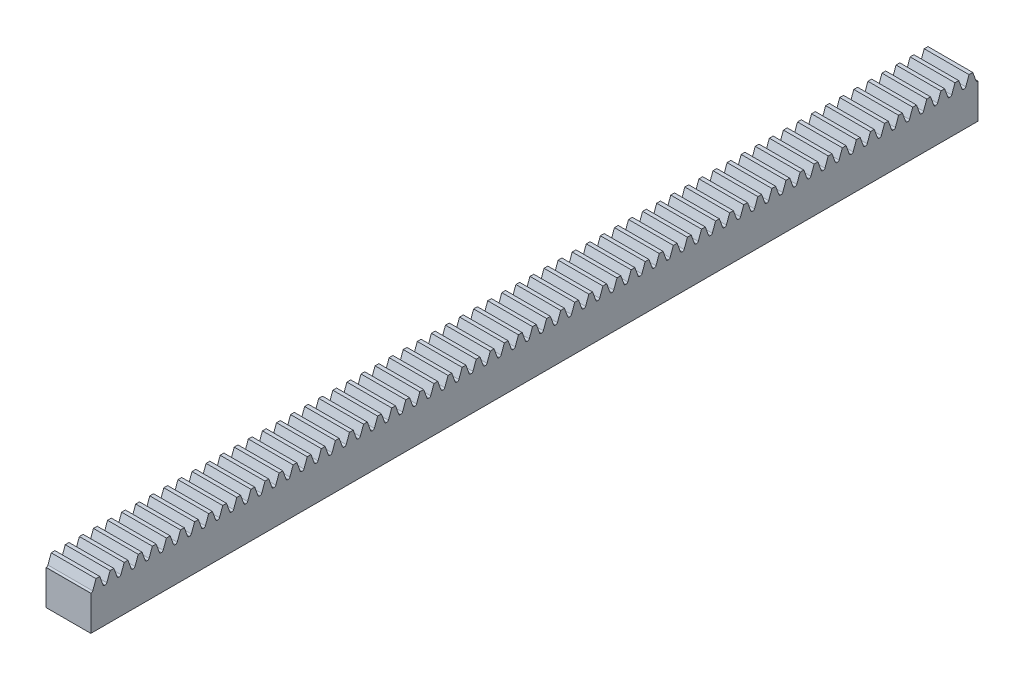
from build123d import *

# Parameters (mm, degrees)
SKETCH1_W                = 296.88
SKETCH1_H                = 15
BOSS_EXTRUDE1_DEPTH      = 15
CUT_EXTRUDE1_DEPTH       = 16
CUT_EXTRUDE2_DEPTH       = 16
CUT_EXTRUDE3_DEPTH       = 16
CUT_EXTRUDE4_DEPTH       = 16
CUT_EXTRUDE5_DEPTH       = 16
CUT_EXTRUDE6_DEPTH       = 16
CUT_EXTRUDE7_DEPTH       = 16
CUT_EXTRUDE8_DEPTH       = 16
CUT_EXTRUDE9_DEPTH       = 16
CUT_EXTRUDE10_DEPTH      = 16
CUT_EXTRUDE11_DEPTH      = 16
CUT_EXTRUDE12_DEPTH      = 16
CUT_EXTRUDE13_DEPTH      = 16
CUT_EXTRUDE14_DEPTH      = 16
CUT_EXTRUDE15_DEPTH      = 16
CUT_EXTRUDE16_DEPTH      = 16
CUT_EXTRUDE17_DEPTH      = 16
CUT_EXTRUDE18_DEPTH      = 16
CUT_EXTRUDE19_DEPTH      = 16
CUT_EXTRUDE20_DEPTH      = 16
CUT_EXTRUDE21_DEPTH      = 16
CUT_EXTRUDE22_DEPTH      = 16
CUT_EXTRUDE23_DEPTH      = 16
CUT_EXTRUDE24_DEPTH      = 16
CUT_EXTRUDE25_DEPTH      = 16
CUT_EXTRUDE26_DEPTH      = 16
CUT_EXTRUDE27_DEPTH      = 16
CUT_EXTRUDE28_DEPTH      = 16
CUT_EXTRUDE29_DEPTH      = 16
CUT_EXTRUDE30_DEPTH      = 16
CUT_EXTRUDE31_DEPTH      = 16
CUT_EXTRUDE32_DEPTH      = 16
CUT_EXTRUDE33_DEPTH      = 16
CUT_EXTRUDE34_DEPTH      = 16
CUT_EXTRUDE35_DEPTH      = 16
CUT_EXTRUDE36_DEPTH      = 16
CUT_EXTRUDE37_DEPTH      = 16
CUT_EXTRUDE38_DEPTH      = 16
CUT_EXTRUDE39_DEPTH      = 16
CUT_EXTRUDE40_DEPTH      = 16
CUT_EXTRUDE41_DEPTH      = 16
CUT_EXTRUDE42_DEPTH      = 16
CUT_EXTRUDE43_DEPTH      = 16
CUT_EXTRUDE44_DEPTH      = 16
CUT_EXTRUDE45_DEPTH      = 16
CUT_EXTRUDE46_DEPTH      = 16
CUT_EXTRUDE47_DEPTH      = 16
CUT_EXTRUDE48_DEPTH      = 16
CUT_EXTRUDE49_DEPTH      = 16
CUT_EXTRUDE50_DEPTH      = 16
CUT_EXTRUDE51_DEPTH      = 16
CUT_EXTRUDE52_DEPTH      = 16
CUT_EXTRUDE53_DEPTH      = 16
CUT_EXTRUDE54_DEPTH      = 16
CUT_EXTRUDE55_DEPTH      = 16
CUT_EXTRUDE56_DEPTH      = 16
CUT_EXTRUDE57_DEPTH      = 16
CUT_EXTRUDE58_DEPTH      = 16
CUT_EXTRUDE59_DEPTH      = 16
CUT_EXTRUDE60_DEPTH      = 16
CUT_EXTRUDE61_DEPTH      = 16
CUT_EXTRUDE62_DEPTH      = 16
CUT_EXTRUDE63_DEPTH      = 16
CUT_EXTRUDE64_DEPTH      = 16
M3_CLEARANCE_HOLE1_D     = 3.242
M3_CLEARANCE_HOLE1_DEPTH = 7.064115214
M3_CLEARANCE_HOLE1_TIP   = 0.935884786
CHAMFER1_SIZE            = 0.379
FILLET1_R                = 0.57


with BuildPart() as part:
    # Sketch1 → Boss-Extrude1 (new body)
    with BuildSketch(Plane(origin=(7.5, 0, 0), x_dir=(0, 0, -1), z_dir=(1, 0, 0))):
        with Locations((-148.44, 7.5)):
            Rectangle(SKETCH1_W, SKETCH1_H)
    extrude(amount=-BOSS_EXTRUDE1_DEPTH)

    # Sketch2 → Cut-Extrude1 (cut, through all)
    with BuildSketch(Plane.ZY.offset(7.5)):
        Polygon((161.943955351, 15), (158.496044649, 15), (159.724444189, 11.625), (160.715555811, 11.625), align=None)
    extrude(amount=-CUT_EXTRUDE1_DEPTH, mode=Mode.SUBTRACT)

    # Sketch3 → Cut-Extrude2 (cut, through all)
    with BuildSketch(Plane.ZY.offset(7.5)):
        Polygon((166.655955351, 15), (163.208044649, 15), (164.436444189, 11.625), (165.427555811, 11.625), align=None)
    extrude(amount=-CUT_EXTRUDE2_DEPTH, mode=Mode.SUBTRACT)

    # Sketch4 → Cut-Extrude3 (cut, through all)
    with BuildSketch(Plane.ZY.offset(7.5)):
        Polygon((171.367955351, 15), (167.920044649, 15), (169.148444189, 11.625), (170.139555811, 11.625), align=None)
    extrude(amount=-CUT_EXTRUDE3_DEPTH, mode=Mode.SUBTRACT)

    # Sketch5 → Cut-Extrude4 (cut, through all)
    with BuildSketch(Plane.ZY.offset(7.5)):
        Polygon((176.079955351, 15), (172.632044649, 15), (173.860444189, 11.625), (174.851555811, 11.625), align=None)
    extrude(amount=-CUT_EXTRUDE4_DEPTH, mode=Mode.SUBTRACT)

    # Sketch6 → Cut-Extrude5 (cut, through all)
    with BuildSketch(Plane.ZY.offset(7.5)):
        Polygon((180.791955351, 15), (177.344044649, 15), (178.572444189, 11.625), (179.563555811, 11.625), align=None)
    extrude(amount=-CUT_EXTRUDE5_DEPTH, mode=Mode.SUBTRACT)

    # Sketch7 → Cut-Extrude6 (cut, through all)
    with BuildSketch(Plane.ZY.offset(7.5)):
        Polygon((185.503955351, 15), (182.056044649, 15), (183.284444189, 11.625), (184.275555811, 11.625), align=None)
    extrude(amount=-CUT_EXTRUDE6_DEPTH, mode=Mode.SUBTRACT)

    # Sketch8 → Cut-Extrude7 (cut, through all)
    with BuildSketch(Plane.ZY.offset(7.5)):
        Polygon((190.215955351, 15), (186.768044649, 15), (187.996444189, 11.625), (188.987555811, 11.625), align=None)
    extrude(amount=-CUT_EXTRUDE7_DEPTH, mode=Mode.SUBTRACT)

    # Sketch9 → Cut-Extrude8 (cut, through all)
    with BuildSketch(Plane.ZY.offset(7.5)):
        Polygon((194.927955351, 15), (191.480044649, 15), (192.708444189, 11.625), (193.699555811, 11.625), align=None)
    extrude(amount=-CUT_EXTRUDE8_DEPTH, mode=Mode.SUBTRACT)

    # Sketch10 → Cut-Extrude9 (cut, through all)
    with BuildSketch(Plane.ZY.offset(7.5)):
        Polygon((199.639955351, 15), (196.192044649, 15), (197.420444189, 11.625), (198.411555811, 11.625), align=None)
    extrude(amount=-CUT_EXTRUDE9_DEPTH, mode=Mode.SUBTRACT)

    # Sketch11 → Cut-Extrude10 (cut, through all)
    with BuildSketch(Plane.ZY.offset(7.5)):
        Polygon((204.351955351, 15), (200.904044649, 15), (202.132444189, 11.625), (203.123555811, 11.625), align=None)
    extrude(amount=-CUT_EXTRUDE10_DEPTH, mode=Mode.SUBTRACT)

    # Sketch12 → Cut-Extrude11 (cut, through all)
    with BuildSketch(Plane.ZY.offset(7.5)):
        Polygon((209.063955351, 15), (205.616044649, 15), (206.844444189, 11.625), (207.835555811, 11.625), align=None)
    extrude(amount=-CUT_EXTRUDE11_DEPTH, mode=Mode.SUBTRACT)

    # Sketch13 → Cut-Extrude12 (cut, through all)
    with BuildSketch(Plane.ZY.offset(7.5)):
        Polygon((213.775955351, 15), (210.328044649, 15), (211.556444189, 11.625), (212.547555811, 11.625), align=None)
    extrude(amount=-CUT_EXTRUDE12_DEPTH, mode=Mode.SUBTRACT)

    # Sketch14 → Cut-Extrude13 (cut, through all)
    with BuildSketch(Plane.ZY.offset(7.5)):
        Polygon((218.487955351, 15), (215.040044649, 15), (216.268444189, 11.625), (217.259555811, 11.625), align=None)
    extrude(amount=-CUT_EXTRUDE13_DEPTH, mode=Mode.SUBTRACT)

    # Sketch15 → Cut-Extrude14 (cut, through all)
    with BuildSketch(Plane.ZY.offset(7.5)):
        Polygon((223.199955351, 15), (219.752044649, 15), (220.980444189, 11.625), (221.971555811, 11.625), align=None)
    extrude(amount=-CUT_EXTRUDE14_DEPTH, mode=Mode.SUBTRACT)

    # Sketch16 → Cut-Extrude15 (cut, through all)
    with BuildSketch(Plane.ZY.offset(7.5)):
        Polygon((227.911955351, 15), (224.464044649, 15), (225.692444189, 11.625), (226.683555811, 11.625), align=None)
    extrude(amount=-CUT_EXTRUDE15_DEPTH, mode=Mode.SUBTRACT)

    # Sketch17 → Cut-Extrude16 (cut, through all)
    with BuildSketch(Plane.ZY.offset(7.5)):
        Polygon((232.623955351, 15), (229.176044649, 15), (230.404444189, 11.625), (231.395555811, 11.625), align=None)
    extrude(amount=-CUT_EXTRUDE16_DEPTH, mode=Mode.SUBTRACT)

    # Sketch18 → Cut-Extrude17 (cut, through all)
    with BuildSketch(Plane.ZY.offset(7.5)):
        Polygon((237.335955351, 15), (233.888044649, 15), (235.116444189, 11.625), (236.107555811, 11.625), align=None)
    extrude(amount=-CUT_EXTRUDE17_DEPTH, mode=Mode.SUBTRACT)

    # Sketch19 → Cut-Extrude18 (cut, through all)
    with BuildSketch(Plane.ZY.offset(7.5)):
        Polygon((242.047955351, 15), (238.600044649, 15), (239.828444189, 11.625), (240.819555811, 11.625), align=None)
    extrude(amount=-CUT_EXTRUDE18_DEPTH, mode=Mode.SUBTRACT)

    # Sketch20 → Cut-Extrude19 (cut, through all)
    with BuildSketch(Plane.ZY.offset(7.5)):
        Polygon((246.759955351, 15), (243.312044649, 15), (244.540444189, 11.625), (245.531555811, 11.625), align=None)
    extrude(amount=-CUT_EXTRUDE19_DEPTH, mode=Mode.SUBTRACT)

    # Sketch21 → Cut-Extrude20 (cut, through all)
    with BuildSketch(Plane.ZY.offset(7.5)):
        Polygon((251.471955351, 15), (248.024044649, 15), (249.252444189, 11.625), (250.243555811, 11.625), align=None)
    extrude(amount=-CUT_EXTRUDE20_DEPTH, mode=Mode.SUBTRACT)

    # Sketch22 → Cut-Extrude21 (cut, through all)
    with BuildSketch(Plane.ZY.offset(7.5)):
        Polygon((256.183955351, 15), (252.736044649, 15), (253.964444189, 11.625), (254.955555811, 11.625), align=None)
    extrude(amount=-CUT_EXTRUDE21_DEPTH, mode=Mode.SUBTRACT)

    # Sketch23 → Cut-Extrude22 (cut, through all)
    with BuildSketch(Plane.ZY.offset(7.5)):
        Polygon((260.895955351, 15), (257.448044649, 15), (258.676444189, 11.625), (259.667555811, 11.625), align=None)
    extrude(amount=-CUT_EXTRUDE22_DEPTH, mode=Mode.SUBTRACT)

    # Sketch24 → Cut-Extrude23 (cut, through all)
    with BuildSketch(Plane.ZY.offset(7.5)):
        Polygon((265.607955351, 15), (262.160044649, 15), (263.388444189, 11.625), (264.379555811, 11.625), align=None)
    extrude(amount=-CUT_EXTRUDE23_DEPTH, mode=Mode.SUBTRACT)

    # Sketch25 → Cut-Extrude24 (cut, through all)
    with BuildSketch(Plane.ZY.offset(7.5)):
        Polygon((270.319955351, 15), (266.872044649, 15), (268.100444189, 11.625), (269.091555811, 11.625), align=None)
    extrude(amount=-CUT_EXTRUDE24_DEPTH, mode=Mode.SUBTRACT)

    # Sketch26 → Cut-Extrude25 (cut, through all)
    with BuildSketch(Plane.ZY.offset(7.5)):
        Polygon((275.031955351, 15), (271.584044649, 15), (272.812444189, 11.625), (273.803555811, 11.625), align=None)
    extrude(amount=-CUT_EXTRUDE25_DEPTH, mode=Mode.SUBTRACT)

    # Sketch27 → Cut-Extrude26 (cut, through all)
    with BuildSketch(Plane.ZY.offset(7.5)):
        Polygon((279.743955351, 15), (276.296044649, 15), (277.524444189, 11.625), (278.515555811, 11.625), align=None)
    extrude(amount=-CUT_EXTRUDE26_DEPTH, mode=Mode.SUBTRACT)

    # Sketch28 → Cut-Extrude27 (cut, through all)
    with BuildSketch(Plane.ZY.offset(7.5)):
        Polygon((284.455955351, 15), (281.008044649, 15), (282.236444189, 11.625), (283.227555811, 11.625), align=None)
    extrude(amount=-CUT_EXTRUDE27_DEPTH, mode=Mode.SUBTRACT)

    # Sketch29 → Cut-Extrude28 (cut, through all)
    with BuildSketch(Plane.ZY.offset(7.5)):
        Polygon((289.167955351, 15), (285.720044649, 15), (286.948444189, 11.625), (287.939555811, 11.625), align=None)
    extrude(amount=-CUT_EXTRUDE28_DEPTH, mode=Mode.SUBTRACT)

    # Sketch30 → Cut-Extrude29 (cut, through all)
    with BuildSketch(Plane.ZY.offset(7.5)):
        Polygon((293.879955351, 15), (290.432044649, 15), (291.660444189, 11.625), (292.651555811, 11.625), align=None)
    extrude(amount=-CUT_EXTRUDE29_DEPTH, mode=Mode.SUBTRACT)

    # Sketch31 → Cut-Extrude30 (cut, through all)
    with BuildSketch(Plane.ZY.offset(7.5)):
        Polygon((296.88, 15), (295.144044649, 15), (296.372444189, 11.625), (296.88, 11.625), align=None)
    extrude(amount=-CUT_EXTRUDE30_DEPTH, mode=Mode.SUBTRACT)

    # Sketch32 → Cut-Extrude31 (cut, through all)
    with BuildSketch(Plane.ZY.offset(7.5)):
        Polygon((0, 15), (0, 11.625), (0.507555811, 11.625), (1.735955351, 15), align=None)
    extrude(amount=-CUT_EXTRUDE31_DEPTH, mode=Mode.SUBTRACT)

    # Sketch33 → Cut-Extrude32 (cut, through all)
    with BuildSketch(Plane.ZY.offset(7.5)):
        Polygon((6.447955351, 15), (3.000044649, 15), (4.228444189, 11.625), (5.219555811, 11.625), align=None)
    extrude(amount=-CUT_EXTRUDE32_DEPTH, mode=Mode.SUBTRACT)

    # Sketch34 → Cut-Extrude33 (cut, through all)
    with BuildSketch(Plane.ZY.offset(7.5)):
        Polygon((11.159955351, 15), (7.712044649, 15), (8.940444189, 11.625), (9.931555811, 11.625), align=None)
    extrude(amount=-CUT_EXTRUDE33_DEPTH, mode=Mode.SUBTRACT)

    # Sketch35 → Cut-Extrude34 (cut, through all)
    with BuildSketch(Plane.ZY.offset(7.5)):
        Polygon((15.871955351, 15), (12.424044649, 15), (13.652444189, 11.625), (14.643555811, 11.625), align=None)
    extrude(amount=-CUT_EXTRUDE34_DEPTH, mode=Mode.SUBTRACT)

    # Sketch36 → Cut-Extrude35 (cut, through all)
    with BuildSketch(Plane.ZY.offset(7.5)):
        Polygon((20.583955351, 15), (17.136044649, 15), (18.364444189, 11.625), (19.355555811, 11.625), align=None)
    extrude(amount=-CUT_EXTRUDE35_DEPTH, mode=Mode.SUBTRACT)

    # Sketch37 → Cut-Extrude36 (cut, through all)
    with BuildSketch(Plane.ZY.offset(7.5)):
        Polygon((25.295955351, 15), (21.848044649, 15), (23.076444189, 11.625), (24.067555811, 11.625), align=None)
    extrude(amount=-CUT_EXTRUDE36_DEPTH, mode=Mode.SUBTRACT)

    # Sketch38 → Cut-Extrude37 (cut, through all)
    with BuildSketch(Plane.ZY.offset(7.5)):
        Polygon((30.007955351, 15), (26.560044649, 15), (27.788444189, 11.625), (28.779555811, 11.625), align=None)
    extrude(amount=-CUT_EXTRUDE37_DEPTH, mode=Mode.SUBTRACT)

    # Sketch39 → Cut-Extrude38 (cut, through all)
    with BuildSketch(Plane.ZY.offset(7.5)):
        Polygon((34.719955351, 15), (31.272044649, 15), (32.500444189, 11.625), (33.491555811, 11.625), align=None)
    extrude(amount=-CUT_EXTRUDE38_DEPTH, mode=Mode.SUBTRACT)

    # Sketch40 → Cut-Extrude39 (cut, through all)
    with BuildSketch(Plane.ZY.offset(7.5)):
        Polygon((39.431955351, 15), (35.984044649, 15), (37.212444189, 11.625), (38.203555811, 11.625), align=None)
    extrude(amount=-CUT_EXTRUDE39_DEPTH, mode=Mode.SUBTRACT)

    # Sketch41 → Cut-Extrude40 (cut, through all)
    with BuildSketch(Plane.ZY.offset(7.5)):
        Polygon((44.143955351, 15), (40.696044649, 15), (41.924444189, 11.625), (42.915555811, 11.625), align=None)
    extrude(amount=-CUT_EXTRUDE40_DEPTH, mode=Mode.SUBTRACT)

    # Sketch42 → Cut-Extrude41 (cut, through all)
    with BuildSketch(Plane.ZY.offset(7.5)):
        Polygon((48.855955351, 15), (45.408044649, 15), (46.636444189, 11.625), (47.627555811, 11.625), align=None)
    extrude(amount=-CUT_EXTRUDE41_DEPTH, mode=Mode.SUBTRACT)

    # Sketch43 → Cut-Extrude42 (cut, through all)
    with BuildSketch(Plane.ZY.offset(7.5)):
        Polygon((53.567955351, 15), (50.120044649, 15), (51.348444189, 11.625), (52.339555811, 11.625), align=None)
    extrude(amount=-CUT_EXTRUDE42_DEPTH, mode=Mode.SUBTRACT)

    # Sketch44 → Cut-Extrude43 (cut, through all)
    with BuildSketch(Plane.ZY.offset(7.5)):
        Polygon((58.279955351, 15), (54.832044649, 15), (56.060444189, 11.625), (57.051555811, 11.625), align=None)
    extrude(amount=-CUT_EXTRUDE43_DEPTH, mode=Mode.SUBTRACT)

    # Sketch45 → Cut-Extrude44 (cut, through all)
    with BuildSketch(Plane.ZY.offset(7.5)):
        Polygon((62.991955351, 15), (59.544044649, 15), (60.772444189, 11.625), (61.763555811, 11.625), align=None)
    extrude(amount=-CUT_EXTRUDE44_DEPTH, mode=Mode.SUBTRACT)

    # Sketch46 → Cut-Extrude45 (cut, through all)
    with BuildSketch(Plane.ZY.offset(7.5)):
        Polygon((67.703955351, 15), (64.256044649, 15), (65.484444189, 11.625), (66.475555811, 11.625), align=None)
    extrude(amount=-CUT_EXTRUDE45_DEPTH, mode=Mode.SUBTRACT)

    # Sketch47 → Cut-Extrude46 (cut, through all)
    with BuildSketch(Plane.ZY.offset(7.5)):
        Polygon((72.415955351, 15), (68.968044649, 15), (70.196444189, 11.625), (71.187555811, 11.625), align=None)
    extrude(amount=-CUT_EXTRUDE46_DEPTH, mode=Mode.SUBTRACT)

    # Sketch48 → Cut-Extrude47 (cut, through all)
    with BuildSketch(Plane.ZY.offset(7.5)):
        Polygon((77.127955351, 15), (73.680044649, 15), (74.908444189, 11.625), (75.899555811, 11.625), align=None)
    extrude(amount=-CUT_EXTRUDE47_DEPTH, mode=Mode.SUBTRACT)

    # Sketch49 → Cut-Extrude48 (cut, through all)
    with BuildSketch(Plane.ZY.offset(7.5)):
        Polygon((81.839955351, 15), (78.392044649, 15), (79.620444189, 11.625), (80.611555811, 11.625), align=None)
    extrude(amount=-CUT_EXTRUDE48_DEPTH, mode=Mode.SUBTRACT)

    # Sketch50 → Cut-Extrude49 (cut, through all)
    with BuildSketch(Plane.ZY.offset(7.5)):
        Polygon((86.551955351, 15), (83.104044649, 15), (84.332444189, 11.625), (85.323555811, 11.625), align=None)
    extrude(amount=-CUT_EXTRUDE49_DEPTH, mode=Mode.SUBTRACT)

    # Sketch51 → Cut-Extrude50 (cut, through all)
    with BuildSketch(Plane.ZY.offset(7.5)):
        Polygon((91.263955351, 15), (87.816044649, 15), (89.044444189, 11.625), (90.035555811, 11.625), align=None)
    extrude(amount=-CUT_EXTRUDE50_DEPTH, mode=Mode.SUBTRACT)

    # Sketch52 → Cut-Extrude51 (cut, through all)
    with BuildSketch(Plane.ZY.offset(7.5)):
        Polygon((95.975955351, 15), (92.528044649, 15), (93.756444189, 11.625), (94.747555811, 11.625), align=None)
    extrude(amount=-CUT_EXTRUDE51_DEPTH, mode=Mode.SUBTRACT)

    # Sketch53 → Cut-Extrude52 (cut, through all)
    with BuildSketch(Plane.ZY.offset(7.5)):
        Polygon((100.687955351, 15), (97.240044649, 15), (98.468444189, 11.625), (99.459555811, 11.625), align=None)
    extrude(amount=-CUT_EXTRUDE52_DEPTH, mode=Mode.SUBTRACT)

    # Sketch54 → Cut-Extrude53 (cut, through all)
    with BuildSketch(Plane.ZY.offset(7.5)):
        Polygon((105.399955351, 15), (101.952044649, 15), (103.180444189, 11.625), (104.171555811, 11.625), align=None)
    extrude(amount=-CUT_EXTRUDE53_DEPTH, mode=Mode.SUBTRACT)

    # Sketch55 → Cut-Extrude54 (cut, through all)
    with BuildSketch(Plane.ZY.offset(7.5)):
        Polygon((110.111955351, 15), (106.664044649, 15), (107.892444189, 11.625), (108.883555811, 11.625), align=None)
    extrude(amount=-CUT_EXTRUDE54_DEPTH, mode=Mode.SUBTRACT)

    # Sketch56 → Cut-Extrude55 (cut, through all)
    with BuildSketch(Plane.ZY.offset(7.5)):
        Polygon((114.823955351, 15), (111.376044649, 15), (112.604444189, 11.625), (113.595555811, 11.625), align=None)
    extrude(amount=-CUT_EXTRUDE55_DEPTH, mode=Mode.SUBTRACT)

    # Sketch57 → Cut-Extrude56 (cut, through all)
    with BuildSketch(Plane.ZY.offset(7.5)):
        Polygon((119.535955351, 15), (116.088044649, 15), (117.316444189, 11.625), (118.307555811, 11.625), align=None)
    extrude(amount=-CUT_EXTRUDE56_DEPTH, mode=Mode.SUBTRACT)

    # Sketch58 → Cut-Extrude57 (cut, through all)
    with BuildSketch(Plane.ZY.offset(7.5)):
        Polygon((124.247955351, 15), (120.800044649, 15), (122.028444189, 11.625), (123.019555811, 11.625), align=None)
    extrude(amount=-CUT_EXTRUDE57_DEPTH, mode=Mode.SUBTRACT)

    # Sketch59 → Cut-Extrude58 (cut, through all)
    with BuildSketch(Plane.ZY.offset(7.5)):
        Polygon((128.959955351, 15), (125.512044649, 15), (126.740444189, 11.625), (127.731555811, 11.625), align=None)
    extrude(amount=-CUT_EXTRUDE58_DEPTH, mode=Mode.SUBTRACT)

    # Sketch60 → Cut-Extrude59 (cut, through all)
    with BuildSketch(Plane.ZY.offset(7.5)):
        Polygon((133.671955351, 15), (130.224044649, 15), (131.452444189, 11.625), (132.443555811, 11.625), align=None)
    extrude(amount=-CUT_EXTRUDE59_DEPTH, mode=Mode.SUBTRACT)

    # Sketch61 → Cut-Extrude60 (cut, through all)
    with BuildSketch(Plane.ZY.offset(7.5)):
        Polygon((138.383955351, 15), (134.936044649, 15), (136.164444189, 11.625), (137.155555811, 11.625), align=None)
    extrude(amount=-CUT_EXTRUDE60_DEPTH, mode=Mode.SUBTRACT)

    # Sketch62 → Cut-Extrude61 (cut, through all)
    with BuildSketch(Plane.ZY.offset(7.5)):
        Polygon((143.095955351, 15), (139.648044649, 15), (140.876444189, 11.625), (141.867555811, 11.625), align=None)
    extrude(amount=-CUT_EXTRUDE61_DEPTH, mode=Mode.SUBTRACT)

    # Sketch63 → Cut-Extrude62 (cut, through all)
    with BuildSketch(Plane.ZY.offset(7.5)):
        Polygon((147.807955351, 15), (144.360044649, 15), (145.588444189, 11.625), (146.579555811, 11.625), align=None)
    extrude(amount=-CUT_EXTRUDE62_DEPTH, mode=Mode.SUBTRACT)

    # Sketch64 → Cut-Extrude63 (cut, through all)
    with BuildSketch(Plane.ZY.offset(7.5)):
        Polygon((152.519955351, 15), (149.072044649, 15), (150.300444189, 11.625), (151.291555811, 11.625), align=None)
    extrude(amount=-CUT_EXTRUDE63_DEPTH, mode=Mode.SUBTRACT)

    # Sketch65 → Cut-Extrude64 (cut, through all)
    with BuildSketch(Plane.ZY.offset(7.5)):
        Polygon((157.231955351, 15), (153.784044649, 15), (155.012444189, 11.625), (156.003555811, 11.625), align=None)
    extrude(amount=-CUT_EXTRUDE64_DEPTH, mode=Mode.SUBTRACT)

    # M3 Clearance Hole1
    with Locations(Plane(origin=(0, 0, 0), x_dir=(-1, 0, 0), z_dir=(0, -1, 0))):
        with Locations((0, -58.44), (0, -238.44)):
            Hole(M3_CLEARANCE_HOLE1_D / 2, depth=M3_CLEARANCE_HOLE1_DEPTH)
            with Locations((0, 0, -(M3_CLEARANCE_HOLE1_DEPTH + M3_CLEARANCE_HOLE1_TIP / 2))):  # 120° drill point
                Cone(0, M3_CLEARANCE_HOLE1_D / 2, M3_CLEARANCE_HOLE1_TIP, mode=Mode.SUBTRACT)

    # Chamfer1
    chamfer1_edges = [part.edges().sort_by_distance(p)[0] for p in [
        (-1.621, 0, 238.44),
        (-1.621, 0, 58.44),
    ]]
    chamfer(chamfer1_edges, length=CHAMFER1_SIZE)

    # Fillet1
    fillet1_edges = [part.edges().sort_by_distance(p)[0] for p in [
        (0, 11.625, 156.003555811),
        (0, 11.625, 155.012444189),
        (0, 11.625, 184.275555811),
        (0, 11.625, 183.284444189),
        (0, 11.625, 188.987555811),
        (0, 11.625, 187.996444189),
        (0, 11.625, 193.699555811),
        (0, 11.625, 192.708444189),
        (0, 11.625, 198.411555811),
        (0, 11.625, 197.420444189),
        (0, 11.625, 203.123555811),
        (0, 11.625, 202.132444189),
        (0, 11.625, 160.715555811),
        (0, 11.625, 207.835555811),
        (0, 11.625, 206.844444189),
        (0, 11.625, 159.724444189),
        (0, 11.625, 212.547555811),
        (0, 11.625, 211.556444189),
        (0, 11.625, 217.259555811),
        (0, 11.625, 216.268444189),
        (0, 11.625, 221.971555811),
        (0, 11.625, 220.980444189),
        (0, 11.625, 226.683555811),
        (0, 11.625, 225.692444189),
        (0, 11.625, 231.395555811),
        (0, 11.625, 230.404444189),
        (0, 11.625, 236.107555811),
        (0, 11.625, 235.116444189),
        (0, 11.625, 240.819555811),
        (0, 11.625, 239.828444189),
        (0, 11.625, 245.531555811),
        (0, 11.625, 244.540444189),
        (0, 11.625, 250.243555811),
        (0, 11.625, 249.252444189),
        (0, 11.625, 254.955555811),
        (0, 11.625, 253.964444189),
        (0, 11.625, 165.427555811),
        (0, 11.625, 164.436444189),
        (0, 11.625, 259.667555811),
        (0, 11.625, 258.676444189),
        (0, 11.625, 264.379555811),
        (0, 11.625, 263.388444189),
        (0, 11.625, 269.091555811),
        (0, 11.625, 268.100444189),
        (0, 11.625, 273.803555811),
        (0, 11.625, 272.812444189),
        (0, 11.625, 278.515555811),
        (0, 11.625, 277.524444189),
        (0, 11.625, 283.227555811),
        (0, 11.625, 282.236444189),
        (0, 11.625, 287.939555811),
        (0, 11.625, 286.948444189),
        (0, 11.625, 292.651555811),
        (0, 11.625, 291.660444189),
        (0, 11.625, 296.372444189),
        (0, 11.625, 0.507555811),
        (0, 11.625, 5.219555811),
        (0, 11.625, 4.228444189),
        (0, 11.625, 170.139555811),
        (0, 11.625, 169.148444189),
        (0, 11.625, 9.931555811),
        (0, 11.625, 8.940444189),
        (0, 11.625, 14.643555811),
        (0, 11.625, 13.652444189),
        (0, 11.625, 19.355555811),
        (0, 11.625, 18.364444189),
        (0, 11.625, 24.067555811),
        (0, 11.625, 23.076444189),
        (0, 11.625, 28.779555811),
        (0, 11.625, 27.788444189),
        (0, 11.625, 33.491555811),
        (0, 11.625, 32.500444189),
        (0, 11.625, 38.203555811),
        (0, 11.625, 37.212444189),
        (0, 11.625, 42.915555811),
        (0, 11.625, 41.924444189),
        (0, 11.625, 47.627555811),
        (0, 11.625, 46.636444189),
        (0, 11.625, 52.339555811),
        (0, 11.625, 51.348444189),
        (0, 11.625, 57.051555811),
        (0, 11.625, 56.060444189),
        (0, 11.625, 174.851555811),
        (0, 11.625, 173.860444189),
        (0, 11.625, 61.763555811),
        (0, 11.625, 60.772444189),
        (0, 11.625, 66.475555811),
        (0, 11.625, 65.484444189),
        (0, 11.625, 71.187555811),
        (0, 11.625, 70.196444189),
        (0, 11.625, 75.899555811),
        (0, 11.625, 74.908444189),
        (0, 11.625, 80.611555811),
        (0, 11.625, 79.620444189),
        (0, 11.625, 85.323555811),
        (0, 11.625, 84.332444189),
        (0, 11.625, 90.035555811),
        (0, 11.625, 89.044444189),
        (0, 11.625, 94.747555811),
        (0, 11.625, 93.756444189),
        (0, 11.625, 99.459555811),
        (0, 11.625, 98.468444189),
        (0, 11.625, 104.171555811),
        (0, 11.625, 103.180444189),
        (0, 11.625, 108.883555811),
        (0, 11.625, 107.892444189),
        (0, 11.625, 179.563555811),
        (0, 11.625, 178.572444189),
        (0, 11.625, 113.595555811),
        (0, 11.625, 112.604444189),
        (0, 11.625, 118.307555811),
        (0, 11.625, 117.316444189),
        (0, 11.625, 123.019555811),
        (0, 11.625, 122.028444189),
        (0, 11.625, 127.731555811),
        (0, 11.625, 126.740444189),
        (0, 11.625, 132.443555811),
        (0, 11.625, 131.452444189),
        (0, 11.625, 137.155555811),
        (0, 11.625, 136.164444189),
        (0, 11.625, 141.867555811),
        (0, 11.625, 140.876444189),
        (0, 11.625, 146.579555811),
        (0, 11.625, 145.588444189),
        (0, 11.625, 151.291555811),
        (0, 11.625, 150.300444189),
    ]]
    fillet(fillet1_edges, radius=FILLET1_R)


solid = part.part
